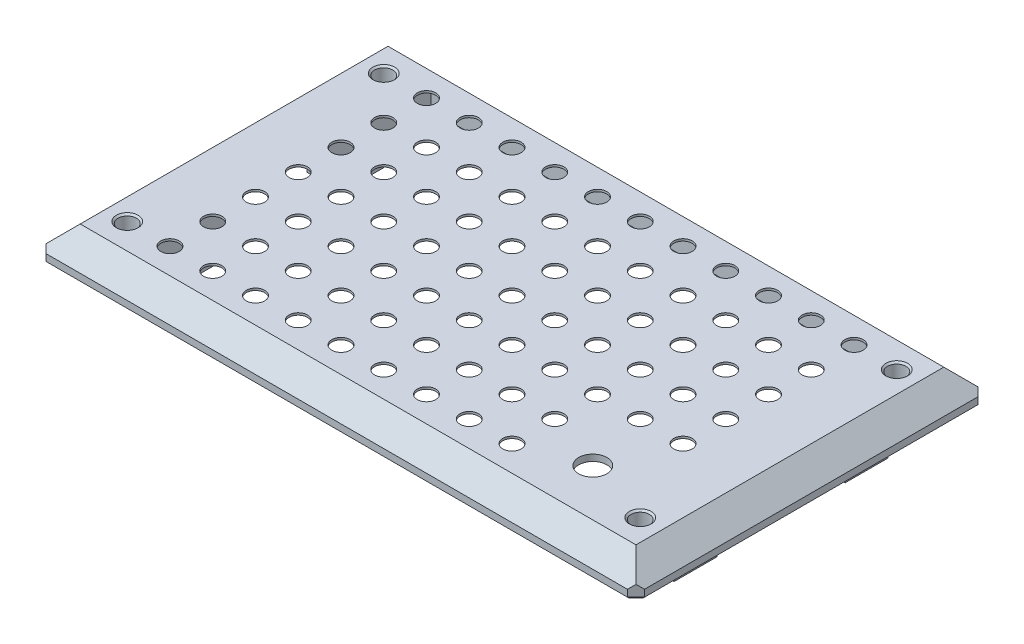
from build123d import *

# Parameters (mm, degrees)
SKETCH1_W           = 140
SKETCH1_H           = 82
BOSS_EXTRUDE1_DEPTH = 2
SKETCH3_W           = 130
SKETCH3_H           = 72
SKETCH2_W           = 140
SKETCH2_H           = 82
CHAMFER2_SIZE       = 2
SKETCH4_W           = 8
SKETCH4_H           = 10
BOSS_EXTRUDE2_DEPTH = 7
SKETCH5_R           = 2.05
CUT_EXTRUDE1_DEPTH  = 133.9000001
SKETCH6_W           = 107.8
SKETCH6_H           = 70
CUT_EXTRUDE2_DEPTH  = 5.5
SKETCH7_R           = 2.15
CUT_EXTRUDE3_DEPTH  = 2.5000001
SKETCH8_R           = 4.2
CUT_EXTRUDE4_DEPTH  = 1
SKETCH13_R          = 4.2
BOSS_EXTRUDE4_DEPTH = 1.5
SKETCH10_R          = 3.3
CUT_EXTRUDE5_DEPTH  = 2.5000001
SKETCH11_W          = 10
SKETCH11_H          = 20
CUT_EXTRUDE6_DEPTH  = 5.5
SKETCH12_R          = 2.15
CUT_EXTRUDE7_DEPTH  = 8.0000001
CHAMFER3_SIZE       = 0.4
CHAMFER4_SIZE       = 0.4
CHAMFER5_SIZE       = 0.4


with BuildPart() as part:
    # Sketch1 → Boss-Extrude1 (new body)
    with BuildSketch(Plane(origin=(0, 0, 0), x_dir=(1, 0, 0), z_dir=(0, 1, 0))):
        Rectangle(SKETCH1_W, SKETCH1_H)
    extrude(amount=BOSS_EXTRUDE1_DEPTH)

    # Sketch3 → Loft1 section 0
    with BuildSketch(Plane(origin=(0, 7, 0), x_dir=(1, 0, 0), z_dir=(0, 1, 0))):
        Rectangle(SKETCH3_W, SKETCH3_H)
    # Sketch2 → Loft1 section 1
    with BuildSketch(Plane(origin=(0, 2, 0), x_dir=(1, 0, 0), z_dir=(0, 1, 0))):
        Rectangle(SKETCH2_W, SKETCH2_H)
    loft()

    # Chamfer2
    chamfer2_edges = [part.edges().sort_by_distance(p)[0] for p in [
        (70, 1, 41),
        (-70, 1, 41),
        (-70, 1, -41),
        (70, 1, -41),
    ]]
    chamfer(chamfer2_edges, length=CHAMFER2_SIZE)

    # Sketch4 → Boss-Extrude2 (add)
    with BuildSketch(Plane.XZ):
        with Locations((-58.9, 20)):
            Rectangle(SKETCH4_W, SKETCH4_H)
        with Locations((-58.9, -20)):
            Rectangle(SKETCH4_W, SKETCH4_H)
        with Locations((58.9, -20)):
            Rectangle(SKETCH4_W, SKETCH4_H)
        with Locations((58.9, 20)):
            Rectangle(SKETCH4_W, SKETCH4_H)
    extrude(amount=BOSS_EXTRUDE2_DEPTH)

    # Sketch5 → Cut-Extrude1 (cut, through all)
    with BuildSketch(Plane.ZY.offset(62.9)):
        with Locations((-20, -3.5)):
            Circle(SKETCH5_R)
        with Locations((20, -3.5)):
            Circle(SKETCH5_R)
    extrude(amount=-CUT_EXTRUDE1_DEPTH, mode=Mode.SUBTRACT)

    # Sketch6 → Cut-Extrude2 (cut)
    with BuildSketch(Plane.XZ):
        Rectangle(SKETCH6_W, SKETCH6_H)
    extrude(amount=-CUT_EXTRUDE2_DEPTH, mode=Mode.SUBTRACT)

    # Sketch7 → Cut-Extrude3 (cut, through all)
    with BuildSketch(Plane.XZ.offset(-5.5)):
        Circle(SKETCH7_R)
        with Locations((10, 0)):
            Circle(SKETCH7_R)
        with Locations((20, 0)):
            Circle(SKETCH7_R)
        with Locations((30, 0)):
            Circle(SKETCH7_R)
        with Locations((40, 0)):
            Circle(SKETCH7_R)
        with Locations((50, 0)):
            Circle(SKETCH7_R)
        with Locations((10, 10)):
            Circle(SKETCH7_R)
        with Locations((20, 10)):
            Circle(SKETCH7_R)
        with Locations((30, 10)):
            Circle(SKETCH7_R)
        with Locations((40, 10)):
            Circle(SKETCH7_R)
        with Locations((50, 10)):
            Circle(SKETCH7_R)
        with Locations((10, 20)):
            Circle(SKETCH7_R)
        with Locations((20, 20)):
            Circle(SKETCH7_R)
        with Locations((30, 20)):
            Circle(SKETCH7_R)
        with Locations((40, 20)):
            Circle(SKETCH7_R)
        with Locations((50, 20)):
            Circle(SKETCH7_R)
        with Locations((10, 30)):
            Circle(SKETCH7_R)
        with Locations((20, 30)):
            Circle(SKETCH7_R)
        with Locations((30, 30)):
            Circle(SKETCH7_R)
        with Locations((40, 30)):
            Circle(SKETCH7_R)
        with Locations((50, 30)):
            Circle(SKETCH7_R)
        with Locations((0, 10)):
            Circle(SKETCH7_R)
        with Locations((0, 20)):
            Circle(SKETCH7_R)
        with Locations((0, 30)):
            Circle(SKETCH7_R)
        with Locations((-50, 30)):
            Circle(SKETCH7_R)
        with Locations((-40, 30)):
            Circle(SKETCH7_R)
        with Locations((-30, 30)):
            Circle(SKETCH7_R)
        with Locations((-20, 30)):
            Circle(SKETCH7_R)
        with Locations((-10, 30)):
            Circle(SKETCH7_R)
        with Locations((-50, 20)):
            Circle(SKETCH7_R)
        with Locations((-40, 20)):
            Circle(SKETCH7_R)
        with Locations((-30, 20)):
            Circle(SKETCH7_R)
        with Locations((-20, 20)):
            Circle(SKETCH7_R)
        with Locations((-10, 20)):
            Circle(SKETCH7_R)
        with Locations((-50, 10)):
            Circle(SKETCH7_R)
        with Locations((-40, 10)):
            Circle(SKETCH7_R)
        with Locations((-30, 10)):
            Circle(SKETCH7_R)
        with Locations((-20, 10)):
            Circle(SKETCH7_R)
        with Locations((-10, 10)):
            Circle(SKETCH7_R)
        with Locations((-50, 0)):
            Circle(SKETCH7_R)
        with Locations((-40, 0)):
            Circle(SKETCH7_R)
        with Locations((-30, 0)):
            Circle(SKETCH7_R)
        with Locations((-20, 0)):
            Circle(SKETCH7_R)
        with Locations((-10, 0)):
            Circle(SKETCH7_R)
        with Locations((-10, -10)):
            Circle(SKETCH7_R)
        with Locations((-20, -10)):
            Circle(SKETCH7_R)
        with Locations((-30, -10)):
            Circle(SKETCH7_R)
        with Locations((-40, -10)):
            Circle(SKETCH7_R)
        with Locations((-50, -10)):
            Circle(SKETCH7_R)
        with Locations((-10, -20)):
            Circle(SKETCH7_R)
        with Locations((-20, -20)):
            Circle(SKETCH7_R)
        with Locations((-30, -20)):
            Circle(SKETCH7_R)
        with Locations((-40, -20)):
            Circle(SKETCH7_R)
        with Locations((-50, -20)):
            Circle(SKETCH7_R)
        with Locations((-10, -30)):
            Circle(SKETCH7_R)
        with Locations((-20, -30)):
            Circle(SKETCH7_R)
        with Locations((-30, -30)):
            Circle(SKETCH7_R)
        with Locations((-40, -30)):
            Circle(SKETCH7_R)
        with Locations((-50, -30)):
            Circle(SKETCH7_R)
        with Locations((0, -30)):
            Circle(SKETCH7_R)
        with Locations((0, -20)):
            Circle(SKETCH7_R)
        with Locations((0, -10)):
            Circle(SKETCH7_R)
        with Locations((50, -30)):
            Circle(SKETCH7_R)
        with Locations((40, -30)):
            Circle(SKETCH7_R)
        with Locations((30, -30)):
            Circle(SKETCH7_R)
        with Locations((20, -30)):
            Circle(SKETCH7_R)
        with Locations((10, -30)):
            Circle(SKETCH7_R)
        with Locations((50, -20)):
            Circle(SKETCH7_R)
        with Locations((40, -20)):
            Circle(SKETCH7_R)
        with Locations((30, -20)):
            Circle(SKETCH7_R)
        with Locations((20, -20)):
            Circle(SKETCH7_R)
        with Locations((10, -20)):
            Circle(SKETCH7_R)
        with Locations((50, -10)):
            Circle(SKETCH7_R)
        with Locations((40, -10)):
            Circle(SKETCH7_R)
        with Locations((30, -10)):
            Circle(SKETCH7_R)
        with Locations((20, -10)):
            Circle(SKETCH7_R)
        with Locations((10, -10)):
            Circle(SKETCH7_R)
    extrude(amount=-CUT_EXTRUDE3_DEPTH, mode=Mode.SUBTRACT)

    # Sketch8 → Cut-Extrude4 (cut)
    with BuildSketch(Plane.XZ.offset(-5.5)):
        Circle(SKETCH8_R)
        with Locations((10, 0)):
            Circle(SKETCH8_R)
        with Locations((20, 0)):
            Circle(SKETCH8_R)
        with Locations((30, 0)):
            Circle(SKETCH8_R)
        with Locations((40, 0)):
            Circle(SKETCH8_R)
        with Locations((50, 0)):
            Circle(SKETCH8_R)
        with Locations((10, 10)):
            Circle(SKETCH8_R)
        with Locations((20, 10)):
            Circle(SKETCH8_R)
        with Locations((30, 10)):
            Circle(SKETCH8_R)
        with Locations((40, 10)):
            Circle(SKETCH8_R)
        with Locations((50, 10)):
            Circle(SKETCH8_R)
        with Locations((10, 20)):
            Circle(SKETCH8_R)
        with Locations((20, 20)):
            Circle(SKETCH8_R)
        with Locations((30, 20)):
            Circle(SKETCH8_R)
        with Locations((40, 20)):
            Circle(SKETCH8_R)
        with Locations((50, 20)):
            Circle(SKETCH8_R)
        with Locations((10, 30)):
            Circle(SKETCH8_R)
        with Locations((20, 30)):
            Circle(SKETCH8_R)
        with Locations((30, 30)):
            Circle(SKETCH8_R)
        with Locations((40, 30)):
            Circle(SKETCH8_R)
        with Locations((50, 30)):
            Circle(SKETCH8_R)
        with Locations((0, 10)):
            Circle(SKETCH8_R)
        with Locations((0, 20)):
            Circle(SKETCH8_R)
        with Locations((0, 30)):
            Circle(SKETCH8_R)
        with Locations((0, -30)):
            Circle(SKETCH8_R)
        with Locations((0, -20)):
            Circle(SKETCH8_R)
        with Locations((0, -10)):
            Circle(SKETCH8_R)
        with Locations((50, -30)):
            Circle(SKETCH8_R)
        with Locations((40, -30)):
            Circle(SKETCH8_R)
        with Locations((30, -30)):
            Circle(SKETCH8_R)
        with Locations((20, -30)):
            Circle(SKETCH8_R)
        with Locations((10, -30)):
            Circle(SKETCH8_R)
        with Locations((50, -20)):
            Circle(SKETCH8_R)
        with Locations((40, -20)):
            Circle(SKETCH8_R)
        with Locations((30, -20)):
            Circle(SKETCH8_R)
        with Locations((20, -20)):
            Circle(SKETCH8_R)
        with Locations((10, -20)):
            Circle(SKETCH8_R)
        with Locations((50, -10)):
            Circle(SKETCH8_R)
        with Locations((40, -10)):
            Circle(SKETCH8_R)
        with Locations((30, -10)):
            Circle(SKETCH8_R)
        with Locations((20, -10)):
            Circle(SKETCH8_R)
        with Locations((10, -10)):
            Circle(SKETCH8_R)
        with Locations((-10, -10)):
            Circle(SKETCH8_R)
        with Locations((-20, -10)):
            Circle(SKETCH8_R)
        with Locations((-30, -10)):
            Circle(SKETCH8_R)
        with Locations((-40, -10)):
            Circle(SKETCH8_R)
        with Locations((-50, -10)):
            Circle(SKETCH8_R)
        with Locations((-10, -20)):
            Circle(SKETCH8_R)
        with Locations((-20, -20)):
            Circle(SKETCH8_R)
        with Locations((-30, -20)):
            Circle(SKETCH8_R)
        with Locations((-40, -20)):
            Circle(SKETCH8_R)
        with Locations((-50, -20)):
            Circle(SKETCH8_R)
        with Locations((-10, -30)):
            Circle(SKETCH8_R)
        with Locations((-20, -30)):
            Circle(SKETCH8_R)
        with Locations((-30, -30)):
            Circle(SKETCH8_R)
        with Locations((-40, -30)):
            Circle(SKETCH8_R)
        with Locations((-50, -30)):
            Circle(SKETCH8_R)
        with Locations((-50, 30)):
            Circle(SKETCH8_R)
        with Locations((-40, 30)):
            Circle(SKETCH8_R)
        with Locations((-30, 30)):
            Circle(SKETCH8_R)
        with Locations((-20, 30)):
            Circle(SKETCH8_R)
        with Locations((-10, 30)):
            Circle(SKETCH8_R)
        with Locations((-50, 20)):
            Circle(SKETCH8_R)
        with Locations((-40, 20)):
            Circle(SKETCH8_R)
        with Locations((-30, 20)):
            Circle(SKETCH8_R)
        with Locations((-20, 20)):
            Circle(SKETCH8_R)
        with Locations((-10, 20)):
            Circle(SKETCH8_R)
        with Locations((-50, 10)):
            Circle(SKETCH8_R)
        with Locations((-40, 10)):
            Circle(SKETCH8_R)
        with Locations((-30, 10)):
            Circle(SKETCH8_R)
        with Locations((-20, 10)):
            Circle(SKETCH8_R)
        with Locations((-10, 10)):
            Circle(SKETCH8_R)
        with Locations((-50, 0)):
            Circle(SKETCH8_R)
        with Locations((-40, 0)):
            Circle(SKETCH8_R)
        with Locations((-30, 0)):
            Circle(SKETCH8_R)
        with Locations((-20, 0)):
            Circle(SKETCH8_R)
        with Locations((-10, 0)):
            Circle(SKETCH8_R)
    extrude(amount=-CUT_EXTRUDE4_DEPTH, mode=Mode.SUBTRACT)

    # Sketch13 → Boss-Extrude4 (add)
    with BuildSketch(Plane.XZ.offset(-5.5)):
        with Locations((50, 20)):
            Circle(SKETCH13_R)
        with Locations((40, 20)):
            Circle(SKETCH13_R)
        with Locations((40, 30)):
            Circle(SKETCH13_R)
        with Locations((50, 30)):
            Circle(SKETCH13_R)
    extrude(amount=-BOSS_EXTRUDE4_DEPTH)

    # Sketch10 → Cut-Extrude5 (cut, through all)
    with BuildSketch(Plane.XZ.offset(-5.5)):
        with Locations((43.9, 25)):
            Circle(SKETCH10_R)
    extrude(amount=-CUT_EXTRUDE5_DEPTH, mode=Mode.SUBTRACT)

    # Sketch11 → Cut-Extrude6 (cut)
    with BuildSketch(Plane.XZ):
        with Locations((58.9, 0)):
            Rectangle(SKETCH11_W, SKETCH11_H)
        with Locations((-58.9, 0)):
            Rectangle(SKETCH11_W, SKETCH11_H)
    extrude(amount=-CUT_EXTRUDE6_DEPTH, mode=Mode.SUBTRACT)

    # Sketch12 → Cut-Extrude7 (cut, through all)
    with BuildSketch(Plane.XZ):
        with Locations((-60, 30)):
            Circle(SKETCH12_R)
        with Locations((-60, -30)):
            Circle(SKETCH12_R)
        with Locations((60, -30)):
            Circle(SKETCH12_R)
        with Locations((60, 30)):
            Circle(SKETCH12_R)
    extrude(amount=-CUT_EXTRUDE7_DEPTH, mode=Mode.SUBTRACT)

    # Chamfer3
    chamfer3_edges = [part.edges().sort_by_distance(p)[0] for p in [
        (0, 0, -41),
        (70, 0, 0),
        (0, 0, 41),
        (-70, 0, 0),
        (69, 0, 40),
        (-69, 0, 40),
        (-69, 0, -40),
        (69, 0, -40),
    ]]
    chamfer(chamfer3_edges, length=CHAMFER3_SIZE)

    # Chamfer4
    chamfer4_edges = [part.edges().sort_by_distance(p)[0] for p in [
        (57.85, 7, 30),
        (57.85, 7, -30),
        (-62.15, 7, -30),
        (-62.15, 7, 30),
    ]]
    chamfer(chamfer4_edges, length=CHAMFER4_SIZE)

    # Chamfer5
    chamfer5_edges = [part.edges().sort_by_distance(p)[0] for p in [
        (62.9, -3.5, -22.05),
        (-62.9, -3.5, -22.05),
        (62.9, -3.5, 17.95),
        (-62.9, -3.5, 17.95),
    ]]
    chamfer(chamfer5_edges, length=CHAMFER5_SIZE)


solid = part.part
